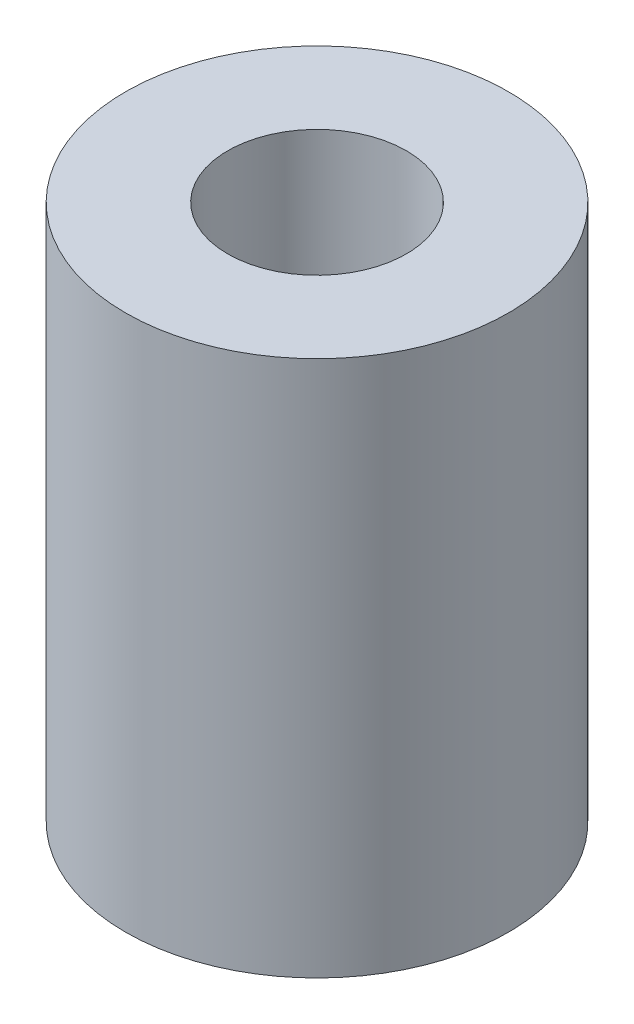
from build123d import *

# Parameters (mm, degrees)
SKETCH1_R                  = 3.75
BOSS_EXTRUDE1_DEPTH        = 10.5
F_3_5_3_5_DIAMETER_HOLE1_D = 3.5


with BuildPart() as part:
    # Sketch1 → Boss-Extrude1 (new body)
    with BuildSketch(Plane(origin=(0, 0, 0), x_dir=(1, 0, 0), z_dir=(0, 1, 0))):
        Circle(SKETCH1_R)
    extrude(amount=BOSS_EXTRUDE1_DEPTH)

    # Ø3.5 (3.5) Diameter Hole1 (through all)
    with Locations(Plane(origin=(0, 10.5, 0), x_dir=(1, 0, 0), z_dir=(0, 1, 0))):
        with Locations((0, 0)):
            Hole(F_3_5_3_5_DIAMETER_HOLE1_D / 2)


solid = part.part
